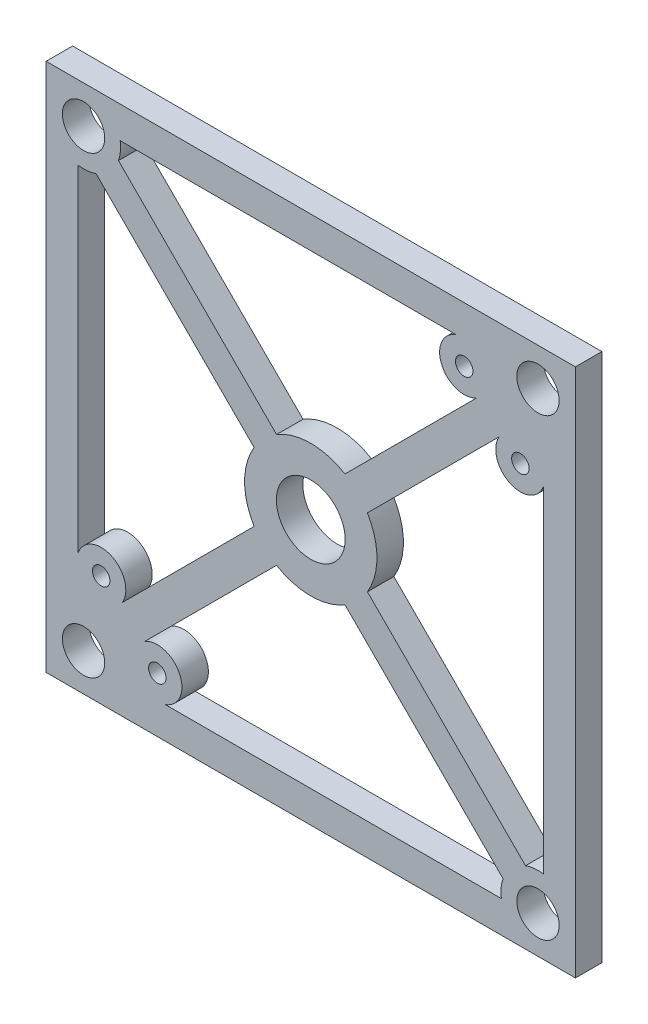
from build123d import *

# Parameters (mm, degrees)
SKETCH1_W                  = 100
SKETCH1_H                  = 100
MAINBODY_DEPTH             = 5
SKETCH2_R                  = 6.5
SKETCH2_R_2                = 4
BEARING_BUSHINGHOLES_DEPTH = 6
M4_TAPPED_HOLE1_D          = 3.3
SKETCH5_R                  = 1.65
SKETCH5_R_2                = 4
CUT_EXTRUDE1_DEPTH         = 6


with BuildPart() as part:
    # Sketch1 → MainBody (new body)
    with BuildSketch(Plane.XY):
        Rectangle(SKETCH1_W, SKETCH1_H)
    extrude(amount=MAINBODY_DEPTH)

    # Sketch2 → Bearing&BushingHoles (cut, through all)
    with BuildSketch(Plane.XY.offset(5)):
        Circle(SKETCH2_R)
        with Locations((-42.928932188, -42.928932188)):
            Circle(SKETCH2_R_2)
        with Locations((42.928932188, -42.928932188)):
            Circle(SKETCH2_R_2)
        with Locations((42.928932188, 42.928932188)):
            Circle(SKETCH2_R_2)
        with Locations((-42.928932188, 42.928932188)):
            Circle(SKETCH2_R_2)
    extrude(amount=-BEARING_BUSHINGHOLES_DEPTH, mode=Mode.SUBTRACT)

    # M4 Tapped Hole1 (through all)
    with Locations(Plane(origin=(-39.597979746, -28.991378029, 0), x_dir=(-1, 0, 0), z_dir=(0, 0, -1))):
        with Locations((0, 0), (-10.606601717, -10.606601717), (-68.589357775, 68.589357775), (-79.195959492, 57.982756058)):
            Hole(M4_TAPPED_HOLE1_D / 2)

    # Sketch5 → Cut-Extrude1 (cut, through all)
    with BuildSketch(Plane(origin=(0, 0, 0), x_dir=(-1, 0, 0), z_dir=(0, 0, -1))):
        with Locations((28.991378029, -39.597979746)):
            Circle(SKETCH5_R)
        with Locations((39.597979746, -28.991378029)):
            Circle(SKETCH5_R)
        with Locations((42.928932188, 42.928932188)):
            Circle(SKETCH5_R_2)
        with Locations((-39.597979746, 28.991378029)):
            Circle(SKETCH5_R)
        with Locations((-28.991378029, 39.597979746)):
            Circle(SKETCH5_R)
        with BuildLine():
            Line((-44, 27.493139834), (-44, -36.011359367))
            ThreePointArc((-44, -36.011359367), (-42.268855308, -35.960123214), (-40.578116577, -36.33547589))
            Line((-40.578116577, -36.33547589), (-10.701821494, -6.459180807))
            ThreePointArc((-10.701821494, -6.459180807), (-12.5, 0), (-10.701821494, 6.459180807))
            Line((-10.701821494, 6.459180807), (-35.587597155, 31.344956468))
            ThreePointArc((-35.587597155, 31.344956468), (-37.66214198, 24.763490596), (-44, 27.493139834))
        make_face()
        with BuildLine():
            Line((44, -27.493139834), (44, 36.011359367))
            ThreePointArc((44, 36.011359367), (42.268855308, 35.960123214), (40.578116577, 36.33547589))
            Line((40.578116577, 36.33547589), (10.701821494, 6.459180807))
            ThreePointArc((10.701821494, 6.459180807), (12.5, 0), (10.701821494, -6.459180807))
            Line((10.701821494, -6.459180807), (35.587597155, -31.344956468))
            ThreePointArc((35.587597155, -31.344956468), (37.66214198, -24.763490596), (44, -27.493139834))
        make_face()
        with BuildLine():
            Line((-27.493139834, 44), (36.011359367, 44))
            ThreePointArc((36.011359367, 44), (35.960123214, 42.268855308), (36.33547589, 40.578116577))
            Line((36.33547589, 40.578116577), (6.459180807, 10.701821494))
            ThreePointArc((6.459180807, 10.701821494), (0, 12.5), (-6.459180807, 10.701821494))
            Line((-6.459180807, 10.701821494), (-31.344956468, 35.587597155))
            ThreePointArc((-31.344956468, 35.587597155), (-24.763490596, 37.66214198), (-27.493139834, 44))
        make_face()
        with BuildLine():
            Line((6.459180807, -10.701821494), (31.344956468, -35.587597155))
            ThreePointArc((31.344956468, -35.587597155), (24.763490596, -37.66214198), (27.493139834, -44))
            Line((27.493139834, -44), (-36.011359367, -44))
            ThreePointArc((-36.011359367, -44), (-35.960123214, -42.268855308), (-36.33547589, -40.578116577))
            Line((-36.33547589, -40.578116577), (-6.459180807, -10.701821494))
            ThreePointArc((-6.459180807, -10.701821494), (0, -12.5), (6.459180807, -10.701821494))
        make_face()
    extrude(amount=-CUT_EXTRUDE1_DEPTH, mode=Mode.SUBTRACT)


solid = part.part
